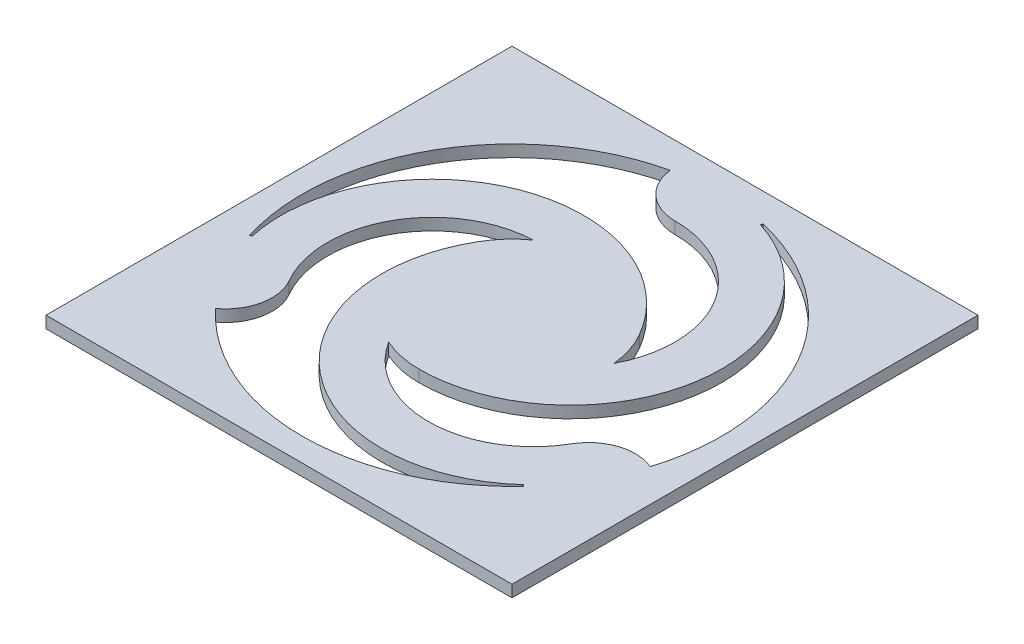
from build123d import *

# Parameters (mm, degrees)
SKETCH1_W           = 5
SKETCH1_H           = 5
BOSS_EXTRUDE1_DEPTH = 0.127


with BuildPart() as part:
    # Sketch1 → Boss-Extrude1 (new body)
    with BuildSketch(Plane(origin=(0, 0, 0), x_dir=(1, 0, 0), z_dir=(0, 1, 0))):
        with Locations((2.5, 2.5)):
            Rectangle(SKETCH1_W, SKETCH1_H)
        with BuildLine():
            ThreePointArc((2.996903995, 4.694444444), (4.448557159, 3.625), (4.648896634, 1.833109261))
            ThreePointArc((4.648896634, 1.833109261), (4.292475213, 1.850014133), (4.015544457, 1.625))
            ThreePointArc((4.015544457, 1.625), (3.062684951, 1.062703919), (2.089108822, 1.588315603))
            ThreePointArc((2.089108822, 1.588315603), (2.289862422, 1.522328174), (2.5, 1.5))
            ThreePointArc((2.5, 1.5), (4.105654072, 2.875), (2.994047407, 4.673076923))
            ThreePointArc((2.994047407, 4.673076923), (2.995590873, 4.683745287), (2.996903995, 4.694444444))
        make_face(mode=Mode.SUBTRACT)
        with BuildLine():
            ThreePointArc((4.151992639, 0.972446295), (2.5, 0.25), (0.848007361, 0.972446295))
            ThreePointArc((0.848007361, 0.972446295), (1.04085812, 1.272663864), (0.984455543, 1.625))
            ThreePointArc((0.984455543, 1.625), (0.973922606, 2.731348579), (1.915903741, 3.311684397))
            ThreePointArc((1.915903741, 3.311684397), (1.758380151, 3.170820393), (1.633974596, 3))
            ThreePointArc((1.633974596, 3), (2.02193249, 0.921962784), (4.134916116, 0.985603933))
            ThreePointArc((4.134916116, 0.985603933), (4.143383457, 0.978933071), (4.151992639, 0.972446295))
        make_face(mode=Mode.SUBTRACT)
        with BuildLine():
            ThreePointArc((0.351103366, 1.833109261), (0.551442841, 3.625), (2.003096005, 4.694444444))
            ThreePointArc((2.003096005, 4.694444444), (2.166666667, 4.377322004), (2.5, 4.25))
            ThreePointArc((2.5, 4.25), (3.463392443, 3.705947502), (3.494987437, 2.6))
            ThreePointArc((3.494987437, 2.6), (3.451757426, 2.806851432), (3.366025404, 3))
            ThreePointArc((3.366025404, 3), (1.372413437, 3.703037216), (0.371036477, 1.841319143))
            ThreePointArc((0.371036477, 1.841319143), (0.36102567, 1.837321642), (0.351103366, 1.833109261))
        make_face(mode=Mode.SUBTRACT)
    extrude(amount=BOSS_EXTRUDE1_DEPTH)


solid = part.part
